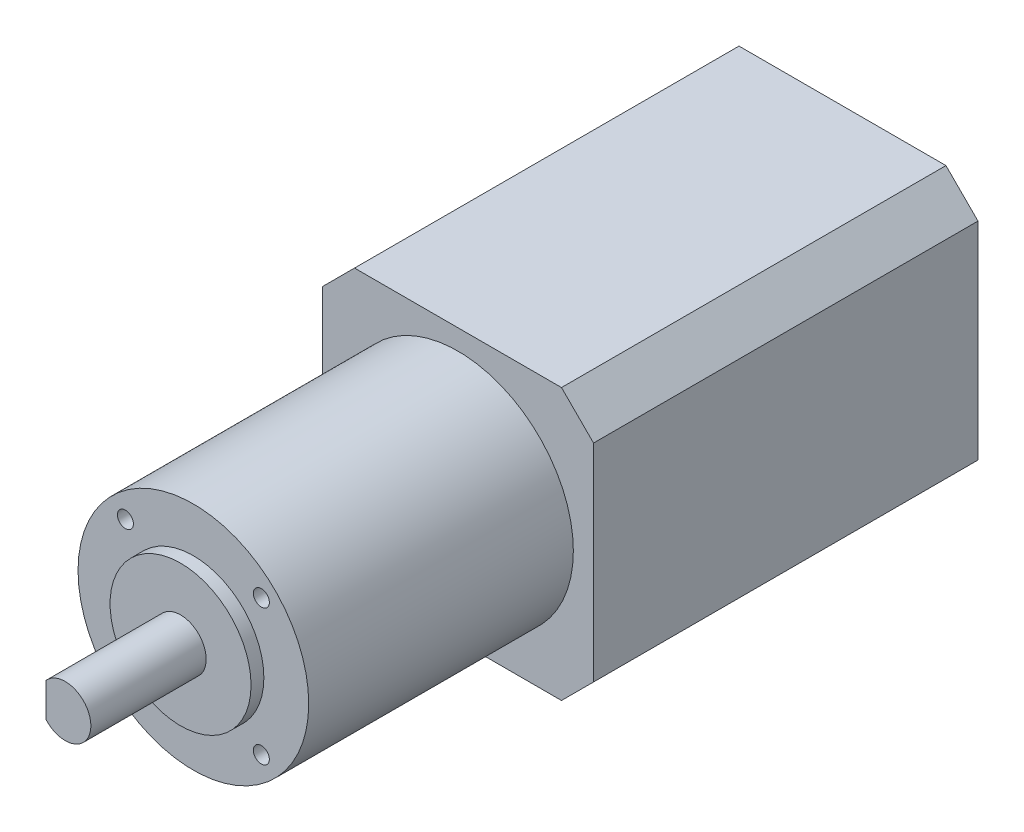
from build123d import *

# Parameters (mm, degrees)
EXTRUDE_1_DEPTH        = 60
SKETCH_2_R             = 18
EXTRUDE_2_DEPTH        = 41.3
SKETCH_3_R             = 11
EXTRUDE_3_DEPTH        = 2
SKETCH_4_R             = 4
EXTRUDE_4_DEPTH        = 18
SKETCH_5_W             = 8.09428643
SKETCH_5_H             = 13.450799509
CUT_EXTRUDE_1_DEPTH    = 15
SKETCH_6_R             = 1
CUT_EXTRUDE_2_DEPTH    = 5
HOLE_WIZARD_M3_1_D     = 2.5
HOLE_WIZARD_M3_1_DEPTH = 7.5
HOLE_WIZARD_M3_1_TIP   = 0.751075774


with BuildPart() as part:
    # 草图1 → 凸台-拉伸1 (new body)
    with BuildSketch(Plane.XY):
        Polygon((-21.15, 16.15), (-16.15, 21.15), (16.15, 21.15), (21.15, 16.15), (21.15, -16.15), (16.15, -21.15), (-16.15, -21.15), (-21.15, -16.15), align=None)
    extrude(amount=EXTRUDE_1_DEPTH)

    # 草图2 → 凸台-拉伸2 (add)
    with BuildSketch(Plane.XY.offset(60)):
        Circle(SKETCH_2_R)
    extrude(amount=EXTRUDE_2_DEPTH)

    # 草图3 → 凸台-拉伸3 (add)
    with BuildSketch(Plane.XY.offset(101.3)):
        Circle(SKETCH_3_R)
    extrude(amount=EXTRUDE_3_DEPTH)

    # 草图4 → 凸台-拉伸4 (add)
    with BuildSketch(Plane.XY.offset(103.3)):
        Circle(SKETCH_4_R)
    extrude(amount=EXTRUDE_4_DEPTH)

    # 草图5 → 切除-拉伸1 (cut)
    with BuildSketch(Plane.XY.offset(121.3)):
        with Locations((-7.047143215, -1.347451383)):
            Rectangle(SKETCH_5_W, SKETCH_5_H)
    extrude(amount=-CUT_EXTRUDE_1_DEPTH, mode=Mode.SUBTRACT)

    # 草图6 → 切除-拉伸2 (cut)
    with BuildSketch(Plane.XY.offset(101.3)):
        with Locations((-10.606601718, 10.606601718)):
            Circle(SKETCH_6_R)
        with Locations((10.606601718, 10.606601718)):
            Circle(SKETCH_6_R)
        with Locations((-10.606601718, -10.606601718)):
            Circle(SKETCH_6_R)
        with Locations((10.606601718, -10.606601718)):
            Circle(SKETCH_6_R)
    extrude(amount=-CUT_EXTRUDE_2_DEPTH, mode=Mode.SUBTRACT)

    # M3 螺纹孔1
    with Locations(Plane.XY.offset(101.3)):
        with Locations((-10.606601718, 10.606601718), (10.606601718, 10.606601718), (-10.606601718, -10.606601718), (10.606601718, -10.606601718)):
            Hole(HOLE_WIZARD_M3_1_D / 2, depth=HOLE_WIZARD_M3_1_DEPTH)
            with Locations((0, 0, -(HOLE_WIZARD_M3_1_DEPTH + HOLE_WIZARD_M3_1_TIP / 2))):  # 118° drill point
                Cone(0, HOLE_WIZARD_M3_1_D / 2, HOLE_WIZARD_M3_1_TIP, mode=Mode.SUBTRACT)


solid = part.part
